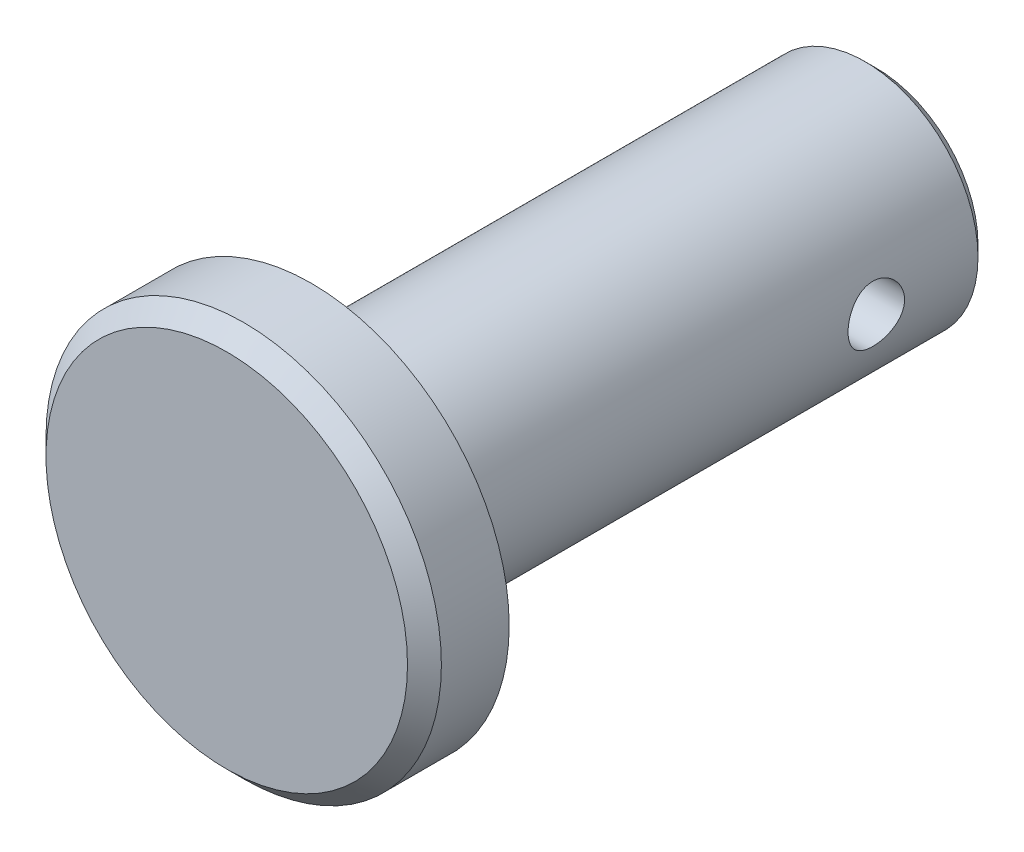
from build123d import *

# Parameters (mm, degrees)
SKETCH1_R           = 4
EXTRUDE1_DEPTH      = 10
SKETCH2_R           = 7
EXTRUDE2_DEPTH      = 3
CHAMFER1_SIZE       = 0.6
SKETCH3_R           = 1
EXTRUDE3_DEPTH      = 8
EXTRUDE3_DEPTH_BACK = 8
CHAMFER2_SIZE       = 0.4


with BuildPart() as part:
    # Sketch1 → Extrude1 (new body, symmetric)
    with BuildSketch(Plane.XY):
        Circle(SKETCH1_R)
    extrude(amount=EXTRUDE1_DEPTH, both=True)

    # Sketch2 → Extrude2 (add)
    with BuildSketch(Plane.XY.offset(10)):
        Circle(SKETCH2_R)
    extrude(amount=EXTRUDE2_DEPTH)

    # Chamfer1
    chamfer1_edges = [part.edges().sort_by_distance(p)[0] for p in [
        (-7, 0, 13),
    ]]
    chamfer(chamfer1_edges, length=CHAMFER1_SIZE)

    # Sketch3 → Extrude3 (cut, two sides)
    with BuildSketch(Plane(origin=(0, 0, 0), x_dir=(0, 0, -1), z_dir=(1, 0, 0))) as extrude3_sk:
        with Locations((6, 0)):
            Circle(SKETCH3_R)
    extrude(amount=EXTRUDE3_DEPTH, mode=Mode.SUBTRACT)
    extrude(extrude3_sk.sketch, amount=-EXTRUDE3_DEPTH_BACK, mode=Mode.SUBTRACT)

    # Chamfer2
    chamfer2_edges = [part.edges().sort_by_distance(p)[0] for p in [
        (-4, 0, -10),
    ]]
    chamfer(chamfer2_edges, length=CHAMFER2_SIZE)


solid = part.part
